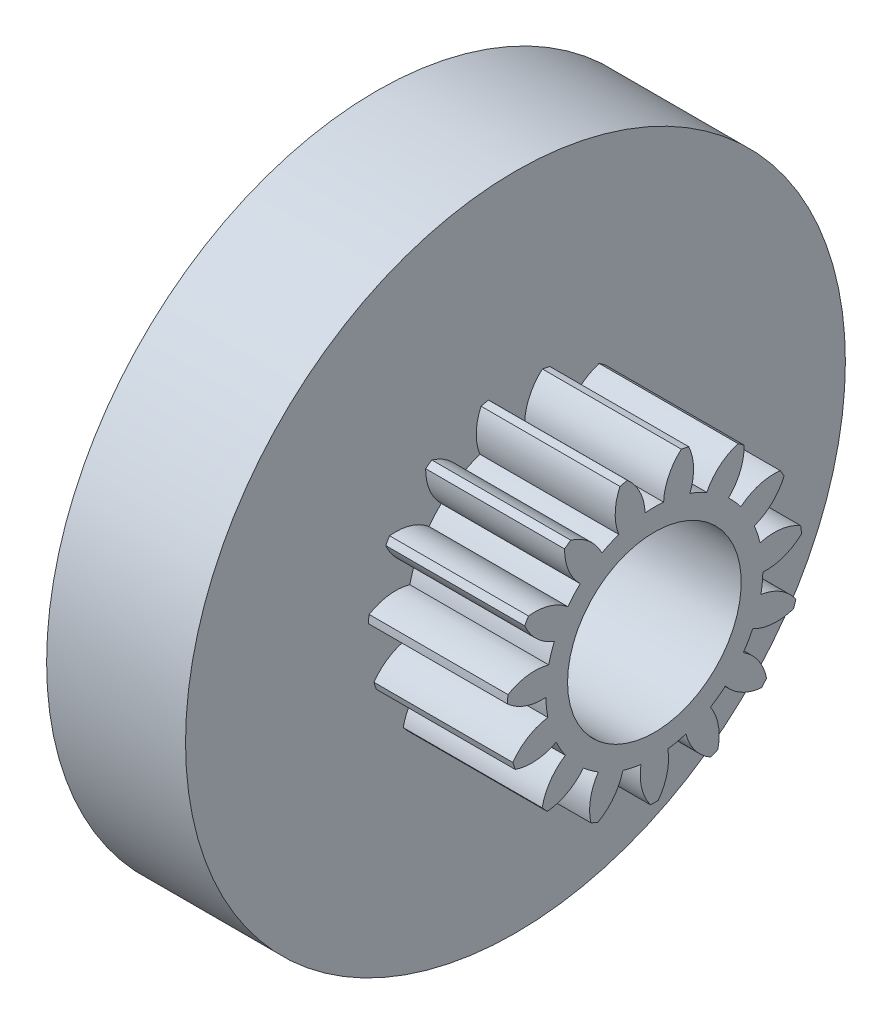
from build123d import *

# Parameters (mm, degrees)
BASPROSKE_W      = 4
BASPROSKE_H      = 4.25
TOOTHCUT_DEPTH   = 8.219764539
TEETHCUTS_COUNT  = 15
TEETHCUTS_ANGLE  = 336
HUBNEAONESKE_R   = 9.5
HUBNEARONE_DEPTH = 4.0001016
BORSKE_R         = 2.5
BORE_DEPTH       = 8.0001016


with BuildPart() as part:
    # BasProSke → Base-Revolve (revolve)
    with BuildSketch(Plane(origin=(0, 0, 0), x_dir=(1, 0, 0), z_dir=(0, 1, 0)), mode=Mode.PRIVATE) as base_revolve_sk:
        with Locations((2, 2.125)):
            Rectangle(BASPROSKE_W, BASPROSKE_H)
    revolve(base_revolve_sk.sketch.rotate(Axis((-10, 0, 0), (1, 0, 0)), 180), axis=Axis((-10, 0, 0), (1, 0, 0)))

    # TooCutSke → ToothCut (cut, through all)
    with BuildSketch(Plane(origin=(0, 0, 0), x_dir=(0, 0, -1), z_dir=(1, 0, 0))):
        with BuildLine():
            ThreePointArc((0.265767165, 3.112674704), (0, 3.124), (-0.265767165, 3.112674704))
            ThreePointArc((-0.265767165, 3.112674704), (-0.418628877, 3.712626775), (-0.800767345, 4.19974009))
            ThreePointArc((-0.800767345, 4.19974009), (0, 4.2754), (0.800767345, 4.19974009))
            ThreePointArc((0.800767345, 4.19974009), (0.418628877, 3.712626775), (0.265767165, 3.112674704))
        make_face()
    toothcut = extrude(amount=TOOTHCUT_DEPTH, mode=Mode.SUBTRACT)

    # TeethCuts: ToothCut ×15 about axis
    teethcuts_axis = Axis((-10, 0, 0), (1, 0, 0))
    for i in range(1, TEETHCUTS_COUNT):
        add(toothcut.rotate(teethcuts_axis, i * TEETHCUTS_ANGLE / (TEETHCUTS_COUNT - 1)), mode=Mode.SUBTRACT)

    # HubNeaOneSke → HubNearOne (add)
    with BuildSketch(Plane.ZY):
        Circle(HUBNEAONESKE_R)
    extrude(amount=HUBNEARONE_DEPTH)

    # BorSke → Bore (cut, symmetric)
    with BuildSketch(Plane(origin=(0, 0, 0), x_dir=(0, 0, -1), z_dir=(1, 0, 0))):
        with Locations(Location((0, 0, 0), (0, 0, 180))):
            Circle(BORSKE_R)
    extrude(amount=BORE_DEPTH, both=True, mode=Mode.SUBTRACT)


solid = part.part
